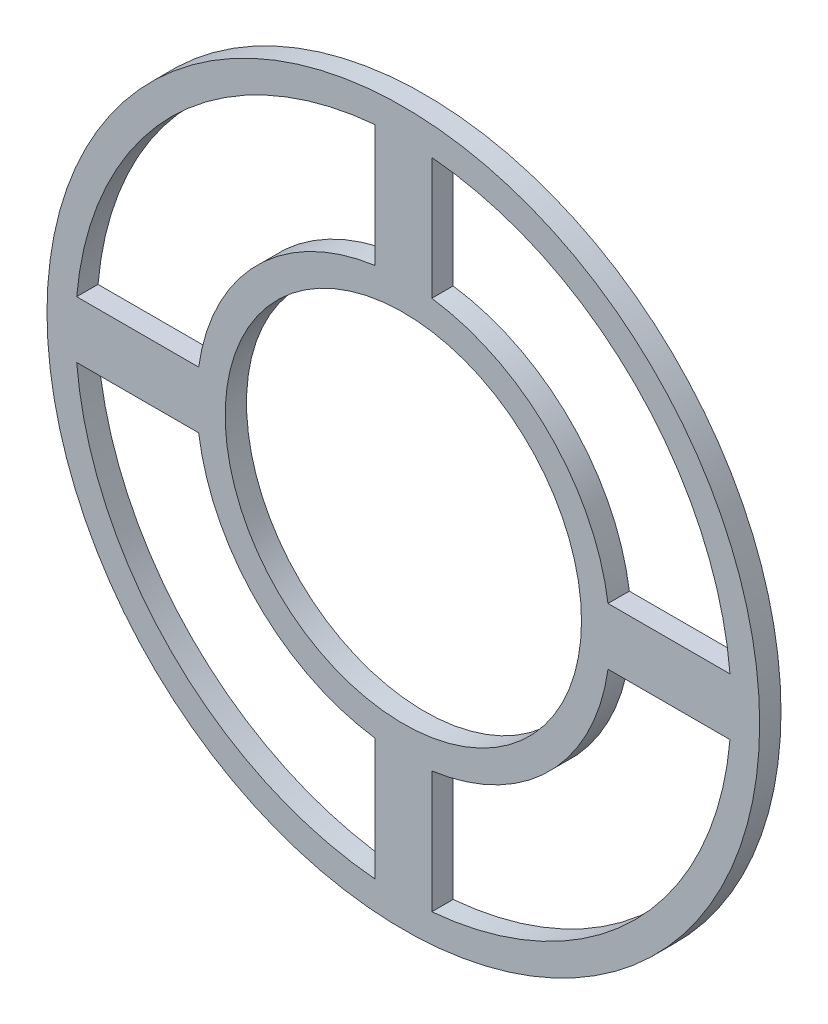
from build123d import *

# Parameters (mm, degrees)
SKETCH1_R           = 79.502
SKETCH1_R_2         = 39.751
BOSS_EXTRUDE1_DEPTH = 4.7625


with BuildPart() as part:
    # Sketch1 → Boss-Extrude1 (new body)
    with BuildSketch(Plane.XY):
        Circle(SKETCH1_R)
        with BuildLine():
            Line((-72.875871206, -6.35), (-45.661577951, -6.35))
            ThreePointArc((-45.661577951, -6.35), (-32.598329719, -32.598329719), (-6.35, -45.661577951))
            Line((-6.35, -45.661577951), (-6.35, -72.875871206))
            ThreePointArc((-6.35, -72.875871206), (-51.726275257, -51.726275257), (-72.875871206, -6.35))
        make_face(mode=Mode.SUBTRACT)
        with BuildLine():
            Line((45.661577951, -6.35), (72.875871206, -6.35))
            ThreePointArc((72.875871206, -6.35), (51.726275257, -51.726275257), (6.35, -72.875871206))
            Line((6.35, -72.875871206), (6.35, -45.661577951))
            ThreePointArc((6.35, -45.661577951), (32.598329719, -32.598329719), (45.661577951, -6.35))
        make_face(mode=Mode.SUBTRACT)
        with BuildLine():
            Line((-6.35, 72.875871206), (-6.35, 45.661577951))
            ThreePointArc((-6.35, 45.661577951), (-32.598329719, 32.598329719), (-45.661577951, 6.35))
            Line((-45.661577951, 6.35), (-72.875871206, 6.35))
            ThreePointArc((-72.875871206, 6.35), (-51.726275257, 51.726275257), (-6.35, 72.875871206))
        make_face(mode=Mode.SUBTRACT)
        Circle(SKETCH1_R_2, mode=Mode.SUBTRACT)
        with BuildLine():
            ThreePointArc((45.661577951, 6.35), (32.598329719, 32.598329719), (6.35, 45.661577951))
            Line((6.35, 45.661577951), (6.35, 72.875871206))
            ThreePointArc((6.35, 72.875871206), (51.726275257, 51.726275257), (72.875871206, 6.35))
            Line((72.875871206, 6.35), (45.661577951, 6.35))
        make_face(mode=Mode.SUBTRACT)
    extrude(amount=BOSS_EXTRUDE1_DEPTH)


solid = part.part
